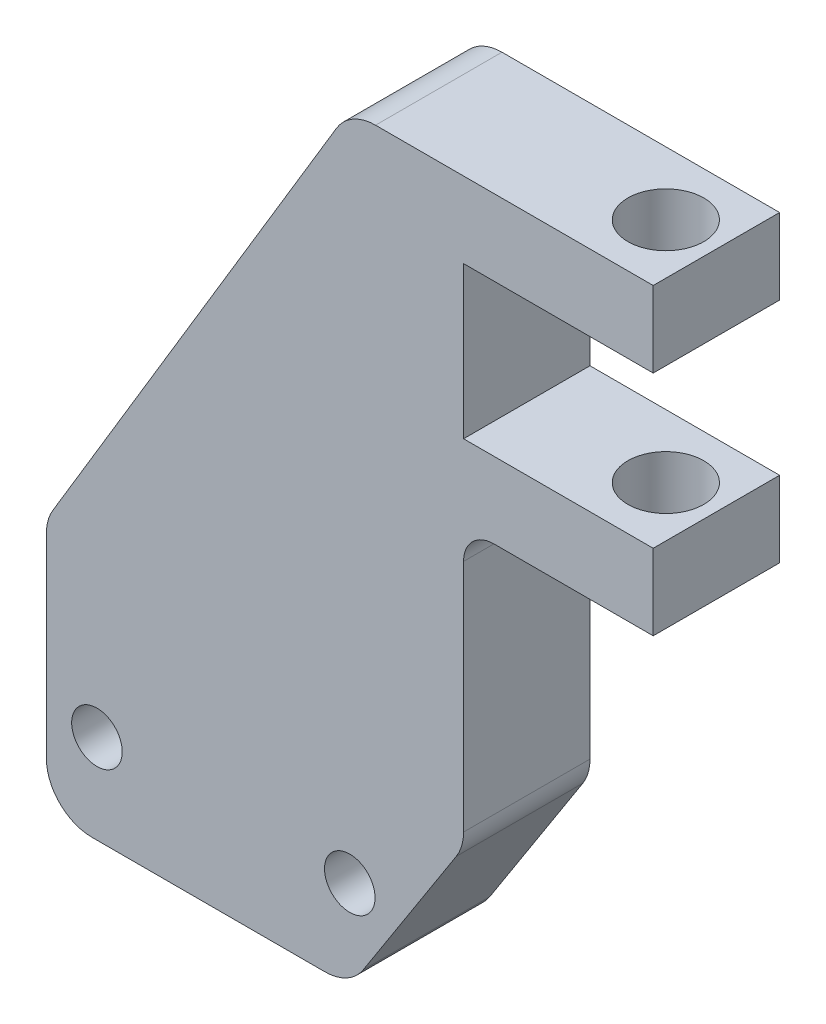
from build123d import *

# Parameters (mm, degrees)
SKETCH1_R      = 1
EXTRUDE1_DEPTH = 5
FILLET2_R      = 1.8
FILLET3_R      = 1.2
SKETCH3_R      = 1.5
EXTRUDE2_DEPTH = 17


with BuildPart() as part:
    # Sketch1 → Extrude1 (new body)
    with BuildSketch(Plane.XY):
        Polygon((7.038618211, 6.213258786), (7.038618211, 16.213258786), (19.038618211, 36.213258786), (31.038618211, 36.213258786), (31.038618211, 33.213258786), (23.538618211, 33.213258786), (23.538618211, 27.213258786), (31.038618211, 27.213258786), (31.038618211, 24.213258786), (23.538618211, 24.213258786), (23.538618211, 13.213258786), (19.038618211, 6.213258786), align=None)
        with Locations((9.038618211, 9.738237996)):
            Circle(SKETCH1_R, mode=Mode.SUBTRACT)
        with Locations((19.038618211, 9.738237996)):
            Circle(SKETCH1_R, mode=Mode.SUBTRACT)
    extrude(amount=EXTRUDE1_DEPTH)

    # Fillet2
    fillet2_edges = [part.edges().sort_by_distance(p)[0] for p in [
        (7.038618211, 6.213258786, 2.5),
        (7.038618211, 16.213258786, 2.5),
        (19.038618211, 36.213258786, 2.5),
        (23.538618211, 13.213258786, 2.5),
        (19.038618211, 6.213258786, 2.5),
    ]]
    fillet(fillet2_edges, radius=FILLET2_R)

    # Fillet3
    fillet3_edges = [part.edges().sort_by_distance(p)[0] for p in [
        (23.538618211, 24.213258786, 2.5),
    ]]
    fillet(fillet3_edges, radius=FILLET3_R)

    # Sketch3 → Extrude2 (cut)
    with BuildSketch(Plane(origin=(0, 36.213258786, 0), x_dir=(1, 0, 0), z_dir=(0, 1, 0))):
        with Locations((29.038618211, -2.5)):
            Circle(SKETCH3_R)
    extrude(amount=-EXTRUDE2_DEPTH, mode=Mode.SUBTRACT)


solid = part.part
